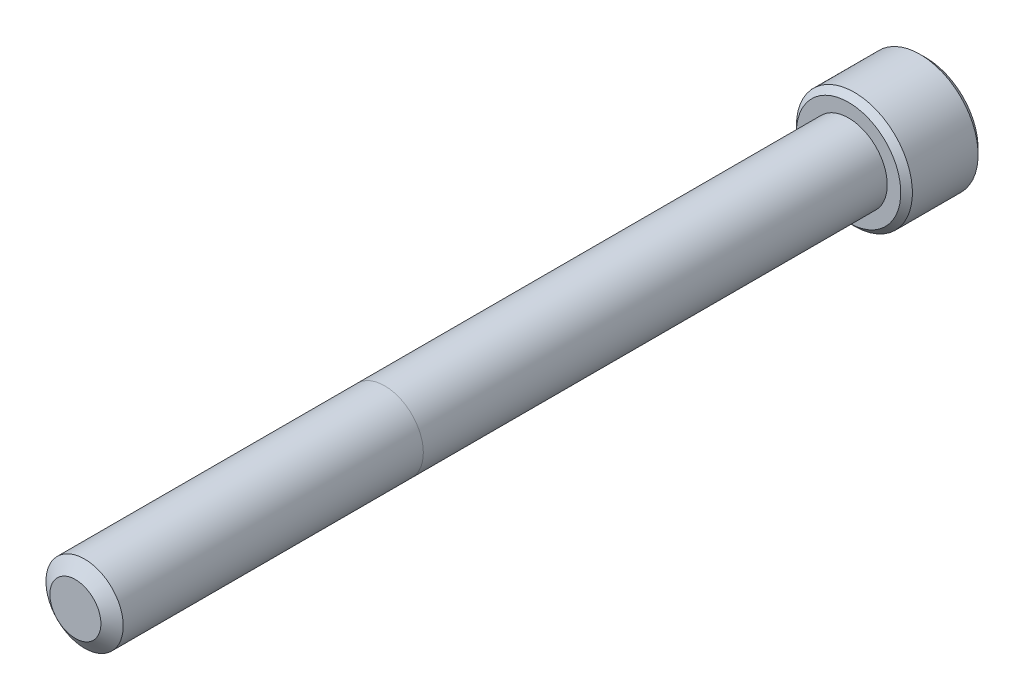
from build123d import *

# Parameters (mm, degrees)
SKETCH1_R          = 3.175
EXTRUDE1_DEPTH     = 63.5
SKETCH6_R          = 4.7625
EXTRUDE2_DEPTH     = 6.35
CUT_EXTRUDE1_DEPTH = 3.571875
CHAMFER1_SIZE      = 0.47625


with BuildPart() as part:
    # Sketch1 → Extrude1 (new body)
    with BuildSketch(Plane.XY):
        Circle(SKETCH1_R)
    extrude(amount=-EXTRUDE1_DEPTH)

    # Sketch4 → Cut-Revolve1 (revolve, cut)
    with BuildSketch(Plane(origin=(0, 0, 0), x_dir=(0, 0, -1), z_dir=(1, 0, 0))):
        Polygon((0.755446349, 3.175), (0, 2.096110803), (0, 3.175), align=None)
    revolve(axis=Axis((0, 0, 0), (0, 0, -1)), mode=Mode.SUBTRACT)

    # Sketch6 → Extrude2 (add)
    with BuildSketch(Plane(origin=(0, 0, -63.5), x_dir=(-1, 0, 0), z_dir=(0, 0, -1))):
        Circle(SKETCH6_R)
    extrude(amount=EXTRUDE2_DEPTH)

    # Sketch7 → Cut-Extrude1 (cut)
    with BuildSketch(Plane(origin=(0, 0, -69.85), x_dir=(-1, 0, 0), z_dir=(0, 0, -1))):
        Polygon((0, 2.749630657), (-2.38125, 1.374815329), (-2.38125, -1.374815329), (0, -2.749630657), (2.38125, -1.374815329), (2.38125, 1.374815329), align=None)
    extrude(amount=-CUT_EXTRUDE1_DEPTH, mode=Mode.SUBTRACT)

    # Cut-Extrude2 cone 1 section (through the dimple's axis) → Cut-Extrude2 (revolve, cut)
    with BuildSketch(Plane(origin=(0, 0, -69.85), x_dir=(0, 1, 0), z_dir=(1, 0, 0))):
        Polygon((0, 0), (2.749630657, 0), (0, 2.749630657), align=None)
    revolve(axis=Axis((0, 0, -69.85), (0, 0, 1)), mode=Mode.SUBTRACT)

    # Chamfer1
    chamfer1_edges = [part.edges().sort_by_distance(p)[0] for p in [
        (4.7625, 0, -69.85),
        (4.7625, 0, -63.5),
    ]]
    chamfer(chamfer1_edges, length=CHAMFER1_SIZE)


solid = part.part
